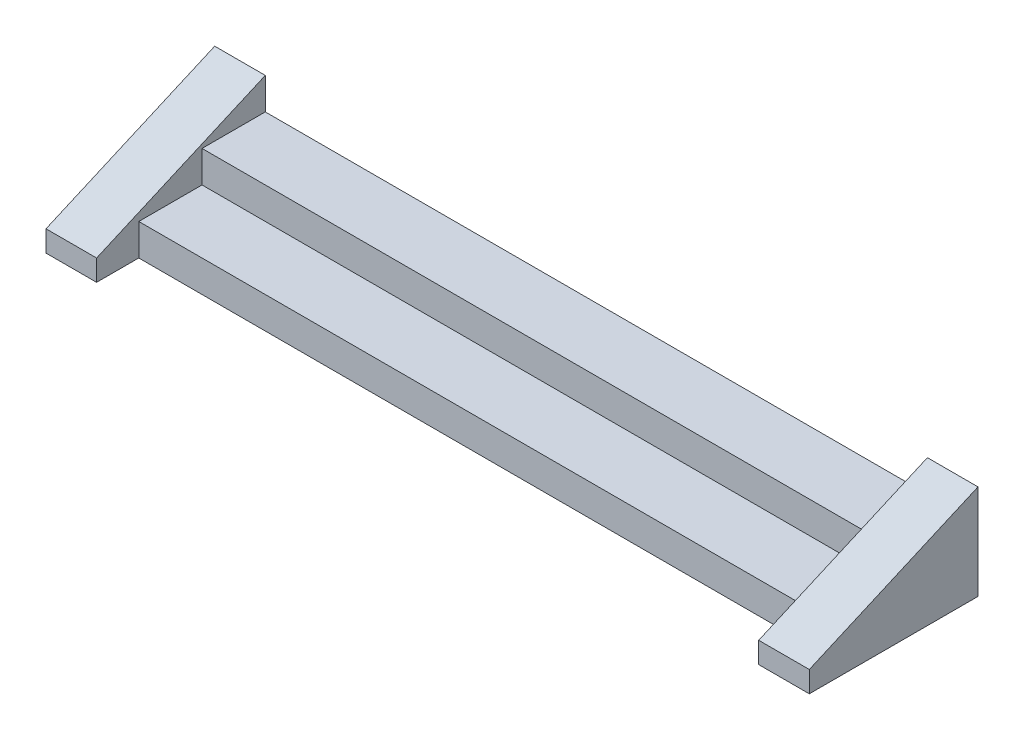
from build123d import *

# Parameters (mm, degrees)
EXTRUDE_1_DEPTH     = 3300
EXTRUDE_2_DEPTH     = 240
CUT_EXTRUDE_1_DEPTH = 160
EXTRUDE_3_DEPTH     = 240


with BuildPart() as part:
    # 草图1 → 凸台-拉伸1 (new body)
    with BuildSketch(Plane(origin=(0, 0, 0), x_dir=(0, 0, -1), z_dir=(1, 0, 0))):
        Polygon((440.145985401, 300), (440.145985401, 0), (-159.854014599, 0), (-159.854014599, 150), (140.145985401, 150), (140.145985401, 300), align=None)
    extrude(amount=EXTRUDE_1_DEPTH)

    # 草图2 → 凸台-拉伸2 (add)
    with BuildSketch(Plane(origin=(3300, 0, 0), x_dir=(0, 0, -1), z_dir=(1, 0, 0))):
        Polygon((440.145985401, 450), (-359.854014599, 100), (-359.854014599, 0), (440.145985401, 0), align=None)
    extrude(amount=EXTRUDE_2_DEPTH)

    # 草图3 → 切除-拉伸1 (cut)
    with BuildSketch(Plane.ZY):
        Polygon((-440.145985401, 300), (-440.145985401, 0), (159.854014599, 0), (159.854014599, 150), (-140.145985401, 150), (-140.145985401, 300), align=None)
    extrude(amount=-CUT_EXTRUDE_1_DEPTH, mode=Mode.SUBTRACT)

    # 草图4 → 凸台-拉伸3 (add)
    with BuildSketch(Plane.ZY.offset(-160)):
        Polygon((-440.145985401, 450), (-440.145985401, 0), (359.854014599, 0), (359.854014599, 100), align=None)
    extrude(amount=EXTRUDE_3_DEPTH)


solid = part.part
